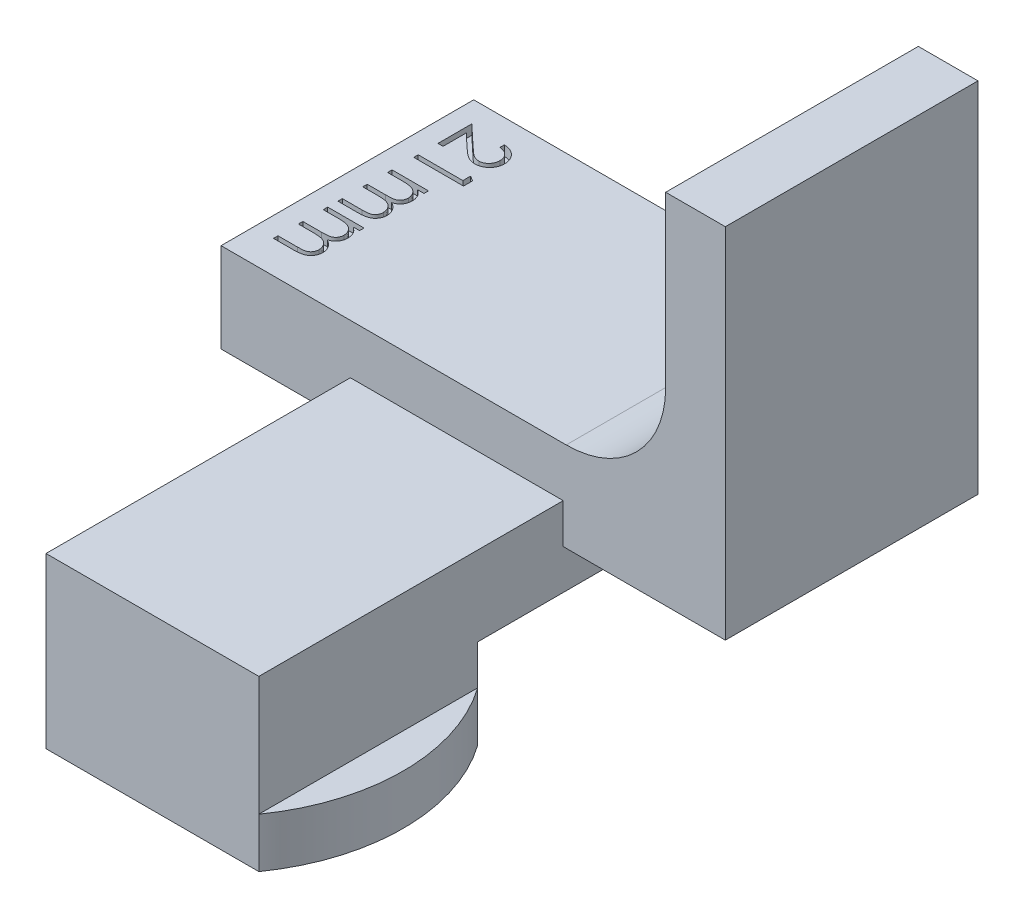
from build123d import *

# Parameters (mm, degrees)
BOSS_EXTRUDE1_DEPTH = 12.7
FILLET1_R           = 5
BOSS_EXTRUDE2_START = -12.7
BOSS_EXTRUDE2_DEPTH = 28
SKETCH4_W           = 14.2
SKETCH4_H           = 4.5
CUT_EXTRUDE2_DEPTH  = 17
SKETCH2_OUTSIDE_W   = 36.354
SKETCH2_OUTSIDE_H   = 39.004
CUT_EXTRUDE1_DEPTH  = 10
CUT_EXTRUDE3_DEPTH  = 0.5


with BuildPart() as part:
    # Sketch1 → Boss-Extrude1 (new body)
    with BuildSketch(Plane.XY):
        Polygon((0, 0), (0, -4), (-1.75, -4), (-1.75, -6.5), (12.45, -6.5), (12.45, -4), (10.7, -4), (10.7, 0), (18.85, 0), (18.85, 18), (15.85, 18), (15.85, 4.5), (-6.5, 4.5), (-6.5, 0), align=None)
    extrude(amount=BOSS_EXTRUDE1_DEPTH)

    # Fillet1
    fillet1_edges = [part.edges().sort_by_distance(p)[0] for p in [
        (15.85, 4.5, 6.35),
    ]]
    fillet(fillet1_edges, radius=FILLET1_R)

    # Sketch3 → Boss-Extrude2 (add)
    with BuildSketch(Plane.XY.offset(12.7).offset(BOSS_EXTRUDE2_START)):
        Polygon((0, 0), (0, 2), (10.7, 2), (10.7, 0), (10.7, -4), (12.45, -4), (12.45, -6.5), (-1.75, -6.5), (-1.75, -4), (0, -4), align=None)
    extrude(amount=BOSS_EXTRUDE2_DEPTH)

    # Sketch4 → Cut-Extrude2 (cut)
    with BuildSketch(Plane(origin=(0, 0, 0), x_dir=(-1, 0, 0), z_dir=(0, 0, -1))):
        with Locations((-5.35, -4.25)):
            Rectangle(SKETCH4_W, SKETCH4_H)
    extrude(amount=-CUT_EXTRUDE2_DEPTH, mode=Mode.SUBTRACT)

    # Sketch2 outside → Cut-Extrude1 (cut)
    with BuildSketch(Plane(origin=(0, -4, 0), x_dir=(1, 0, 0), z_dir=(0, 1, 0))):
        with Locations((6.175, -14)):
            Rectangle(SKETCH2_OUTSIDE_W, SKETCH2_OUTSIDE_H)
        with BuildLine():
            Line((0, -28), (10.7, -28))
            ThreePointArc((10.7, -28), (12.45, -22.5), (10.7, -17))
            Line((10.7, -17), (0, -17))
            ThreePointArc((0, -17), (-1.75, -22.5), (0, -28))
        make_face(mode=Mode.SUBTRACT)
    extrude(amount=-CUT_EXTRUDE1_DEPTH, mode=Mode.SUBTRACT)

    # Sketch5 → Cut-Extrude3 (cut)
    with BuildSketch(Plane(origin=(0, 4.5, 0), x_dir=(1, 0, 0), z_dir=(0, 1, 0))):
        with BuildLine():
            Line((-3.769230769, -1.416666667), (-3.769230769, -1.192307692))
            add(Edge.make_bspline(
                [(-3.769230769, -1.192307692), (-3.739465703, -1.193769696), (-3.681007904, -1.196641031), (-3.595778619, -1.210093331), (-3.514303391, -1.229324068), (-3.437280723, -1.25657851), (-3.363790512, -1.290235363), (-3.294808625, -1.331441091), (-3.229650424, -1.379317255), (-3.169549571, -1.433776024), (-3.114609876, -1.492868808), (-3.06666458, -1.556241548), (-3.026618971, -1.623242893), (-2.992959714, -1.693291702), (-2.967725032, -1.76719811), (-2.948993088, -1.844255655), (-2.93772487, -1.924812628), (-2.936513511, -1.979698296), (-2.935897436, -2.007612179)],
                knots=[0, 0, 0, 0, 8.9345e-05, 0.000175471, 0.000258432, 0.000340159, 0.000420153, 0.000500544, 0.000580775, 0.000662333, 0.000743489, 0.000822516, 0.000900244, 0.000977304, 0.001055226, 0.001134057, 0.001214939, 0.001298647, 0.001298647, 0.001298647, 0.001298647], degree=3))
            add(Edge.make_bspline(
                [(-2.935897436, -2.007612179), (-2.936539191, -2.03502509), (-2.937800215, -2.088890479), (-2.948629522, -2.167506203), (-2.965590659, -2.242347128), (-2.989387385, -2.313266961), (-3.021376262, -2.379699864), (-3.059803075, -2.442144896), (-3.104245812, -2.501345475), (-3.156569964, -2.554636035), (-3.21242881, -2.603570377), (-3.272063027, -2.645786274), (-3.333655374, -2.681938533), (-3.397675518, -2.712072591), (-3.464726252, -2.734255547), (-3.533831397, -2.751097124), (-3.605706262, -2.760616705), (-3.654353802, -2.762077722), (-3.679086538, -2.762820513)],
                knots=[0, 0, 0, 0, 8.2206e-05, 0.000161532, 0.000237582, 0.000312174, 0.000385423, 0.000458258, 0.000531878, 0.000606964, 0.000681872, 0.000754411, 0.000825787, 0.000895917, 0.000966233, 0.001037292, 0.001109039, 0.001183241, 0.001183241, 0.001183241, 0.001183241], degree=3))
            add(Edge.make_bspline(
                [(-3.679086538, -2.762820513), (-3.71390642, -2.761611039), (-3.782935144, -2.759213317), (-3.884374332, -2.738703048), (-3.982655346, -2.706669826), (-4.061753419, -2.668100285), (-4.125491628, -2.629191397), (-4.177969275, -2.594128891), (-4.234473181, -2.553082598), (-4.294814136, -2.505455099), (-4.359464783, -2.452231619), (-4.428386065, -2.392930074), (-4.500865901, -2.327127586), (-4.550369902, -2.280942943), (-4.576021635, -2.257011218)],
                knots=[0, 0, 0, 0, 0.00010437, 0.000206908, 0.000309214, 0.000413814, 0.000469985, 0.000533183, 0.000603103, 0.000679442, 0.000763763, 0.000854314, 0.000952177, 0.001057422, 0.001057422, 0.001057422, 0.001057422], degree=3))
            Line((-4.576021635, -2.257011218), (-5.243589744, -1.631510417))
            Line((-5.243589744, -1.631510417), (-5.243589744, -2.794871795))
            Line((-5.243589744, -2.794871795), (-5.5, -2.794871795))
            Line((-5.5, -2.794871795), (-5.5, -1.096153846))
            Line((-5.5, -1.096153846), (-4.465344551, -2.065705128))
            add(Edge.make_bspline(
                [(-4.465344551, -2.065705128), (-4.440704248, -2.089312433), (-4.393375267, -2.134657234), (-4.324255471, -2.198765658), (-4.260207374, -2.256437951), (-4.200947164, -2.307712368), (-4.146810791, -2.352631099), (-4.097374002, -2.391050425), (-4.053061049, -2.42314015), (-4.001004044, -2.457148572), (-3.937370093, -2.489577858), (-3.85999724, -2.518079883), (-3.780171816, -2.535334621), (-3.726244495, -2.53741506), (-3.69911859, -2.538461538)],
                knots=[0, 0, 0, 0, 0.000102371, 0.000196633, 0.000282807, 0.00036092, 0.00043171, 0.000493817, 0.000548716, 0.000595807, 0.000680247, 0.000762311, 0.000842655, 0.000923972, 0.000923972, 0.000923972, 0.000923972], degree=3))
            add(Edge.make_bspline(
                [(-3.69911859, -2.538461538), (-3.682058563, -2.538012101), (-3.648436526, -2.537126347), (-3.599173745, -2.529161064), (-3.551469794, -2.517458483), (-3.5059145, -2.49942119), (-3.461611877, -2.477750046), (-3.419908864, -2.450063563), (-3.379383905, -2.418425182), (-3.341426566, -2.381726212), (-3.30665175, -2.341437563), (-3.275849492, -2.298868859), (-3.250107098, -2.253833431), (-3.229004646, -2.206518962), (-3.21245079, -2.157057938), (-3.200980379, -2.105354542), (-3.193778604, -2.051551675), (-3.192804196, -2.014813464), (-3.192307692, -1.99609375)],
                knots=[0, 0, 0, 0, 5.1143e-05, 0.000100793, 0.000149379, 0.000198206, 0.000247478, 0.000297068, 0.000348064, 0.000401546, 0.00045516, 0.000507556, 0.000558926, 0.000610487, 0.000662748, 0.000715112, 0.000769155, 0.0008253, 0.0008253, 0.0008253, 0.0008253], degree=3))
            add(Edge.make_bspline(
                [(-3.192307692, -1.99609375), (-3.192818275, -1.976543068), (-3.193820976, -1.938148758), (-3.200839356, -1.881779251), (-3.212935551, -1.827999215), (-3.229519178, -1.776699782), (-3.250398096, -1.727831527), (-3.276905454, -1.681836316), (-3.308006308, -1.638294229), (-3.343459583, -1.597285236), (-3.383118274, -1.559604405), (-3.426783108, -1.525801638), (-3.474738119, -1.496971452), (-3.525900148, -1.471414789), (-3.581629531, -1.451860159), (-3.640575816, -1.43514505), (-3.703576488, -1.423002759), (-3.746982525, -1.418813776), (-3.769230769, -1.416666667)],
                knots=[0, 0, 0, 0, 5.8647e-05, 0.000115173, 0.000170091, 0.000223779, 0.000276715, 0.000329204, 0.000382705, 0.000437025, 0.000491578, 0.000546571, 0.000602313, 0.000659202, 0.000717819, 0.000779181, 0.000842925, 0.000909953, 0.000909953, 0.000909953, 0.000909953], degree=3))
        make_face()
        Polygon((-3, -3.550580929), (-3, -4.012820513), (-5.5, -4.012820513), (-5.5, -3.788461538), (-3.256410256, -3.788461538), (-3.256410256, -3.403846154), align=None)
        with BuildLine():
            Line((-3.673076923, -5.102564103), (-3.673076923, -5.326923077))
            Line((-3.673076923, -5.326923077), (-3.990584936, -5.326923077))
            add(Edge.make_bspline(
                [(-3.990584936, -5.326923077), (-3.962849174, -5.34716972), (-3.90979484, -5.385898498), (-3.839103141, -5.448797063), (-3.780096742, -5.512713891), (-3.748715772, -5.558420094), (-3.733673878, -5.580328526)],
                knots=[0, 0, 0, 0, 0.000102966, 0.000196958, 0.000283467, 0.000363109, 0.000363109, 0.000363109, 0.000363109], degree=3))
            add(Edge.make_bspline(
                [(-3.733673878, -5.580328526), (-3.719384332, -5.610231856), (-3.691054893, -5.66951607), (-3.662316637, -5.763386945), (-3.64465585, -5.85944028), (-3.642240584, -5.92430329), (-3.641025641, -5.95693109)],
                knots=[0, 0, 0, 0, 9.9308e-05, 0.000196881, 0.000293544, 0.000391385, 0.000391385, 0.000391385, 0.000391385], degree=3))
            add(Edge.make_bspline(
                [(-3.641025641, -5.95693109), (-3.641774259, -5.978996712), (-3.643255733, -6.022663392), (-3.652841119, -6.087378046), (-3.669609496, -6.150240939), (-3.692373764, -6.210844306), (-3.720823163, -6.267595926), (-3.753536683, -6.319722966), (-3.790488617, -6.366585325), (-3.833109774, -6.408107089), (-3.882637794, -6.445441216), (-3.940397397, -6.479783522), (-4.007688759, -6.511515734), (-4.056521976, -6.529102395), (-4.082231571, -6.538361378)],
                knots=[0, 0, 0, 0, 6.6199e-05, 0.000131004, 0.000195748, 0.000261045, 0.000324875, 0.00038587, 0.00044539, 0.00050347, 0.000563868, 0.000631031, 0.000704732, 0.000786676, 0.000786676, 0.000786676, 0.000786676], degree=3))
            add(Edge.make_bspline(
                [(-4.082231571, -6.538361378), (-4.064571271, -6.548155129), (-4.029818282, -6.567427856), (-3.980633806, -6.599789024), (-3.934628967, -6.633694597), (-3.891767192, -6.669433505), (-3.852260399, -6.706879695), (-3.815977042, -6.746209064), (-3.782764696, -6.787198937), (-3.743952279, -6.844189786), (-3.702887596, -6.918231383), (-3.666820915, -7.011609342), (-3.644996157, -7.10893871), (-3.642355706, -7.17510418), (-3.641025641, -7.208433494)],
                knots=[0, 0, 0, 0, 6.0564e-05, 0.000119181, 0.000176474, 0.000231939, 0.000286492, 0.000339652, 0.000392367, 0.000444597, 0.000546357, 0.000645594, 0.000744022, 0.000843928, 0.000843928, 0.000843928, 0.000843928], degree=3))
            add(Edge.make_bspline(
                [(-3.641025641, -7.208433494), (-3.642180799, -7.23906311), (-3.644441555, -7.299008243), (-3.662194036, -7.386277718), (-3.692678069, -7.467664722), (-3.734273524, -7.543005491), (-3.786544369, -7.610976786), (-3.848736396, -7.670059864), (-3.920409698, -7.719895838), (-3.987832547, -7.752452009), (-4.047357785, -7.774534341), (-4.098076565, -7.788149508), (-4.153899102, -7.800177862), (-4.214892146, -7.810164466), (-4.281271152, -7.817463431), (-4.352927492, -7.822871085), (-4.429916858, -7.826531138), (-4.483035072, -7.826789761), (-4.510416667, -7.826923077)],
                knots=[0, 0, 0, 0, 9.1843e-05, 0.000179747, 0.000265793, 0.000351646, 0.00043699, 0.000522005, 0.000607999, 0.000697811, 0.000745818, 0.000798306, 0.00085518, 0.000917093, 0.000983624, 0.00105545, 0.001132653, 0.001214791, 0.001214791, 0.001214791, 0.001214791], degree=3))
            Line((-4.510416667, -7.826923077), (-5.5, -7.826923077))
            Line((-5.5, -7.826923077), (-5.5, -7.602564103))
            Line((-5.5, -7.602564103), (-4.509415064, -7.602564103))
            add(Edge.make_bspline(
                [(-4.509415064, -7.602564103), (-4.486043226, -7.602508472), (-4.441126106, -7.602401558), (-4.37666007, -7.600477536), (-4.317896958, -7.596852311), (-4.264916893, -7.592613284), (-4.217596337, -7.586724846), (-4.176030302, -7.579120619), (-4.139891931, -7.571065101), (-4.09983021, -7.557682379), (-4.055638935, -7.536290165), (-4.007972189, -7.503709763), (-3.966512436, -7.462646464), (-3.930306263, -7.415180793), (-3.901462215, -7.361006762), (-3.880083749, -7.301550172), (-3.867445823, -7.237011557), (-3.866083249, -7.192297345), (-3.865384615, -7.169370994)],
                knots=[0, 0, 0, 0, 7.0114e-05, 0.000134748, 0.000193447, 0.000246723, 0.00029418, 0.00033642, 0.000373469, 0.000405143, 0.000462933, 0.000520167, 0.000577538, 0.000637235, 0.000698627, 0.000760882, 0.000826196, 0.000894922, 0.000894922, 0.000894922, 0.000894922], degree=3))
            add(Edge.make_bspline(
                [(-3.865384615, -7.169370994), (-3.866418184, -7.141041216), (-3.868466848, -7.084888039), (-3.888606496, -7.003053701), (-3.919724694, -6.924627707), (-3.964153253, -6.851718167), (-4.017610819, -6.784563992), (-4.081140155, -6.726776322), (-4.15302033, -6.679039661), (-4.219553274, -6.646715238), (-4.279317224, -6.626294332), (-4.331529618, -6.612810815), (-4.390873599, -6.60232268), (-4.456950377, -6.592486587), (-4.530214792, -6.586066782), (-4.610327936, -6.58023223), (-4.697530764, -6.577503042), (-4.757978398, -6.577121286), (-4.789362981, -6.576923077)],
                knots=[0, 0, 0, 0, 8.4849e-05, 0.00016818, 0.000251319, 0.00033712, 0.000423311, 0.000508035, 0.000593596, 0.0006814, 0.000729071, 0.000782881, 0.000842994, 0.000909781, 0.000983233, 0.001063551, 0.001150742, 0.001244898, 0.001244898, 0.001244898, 0.001244898], degree=3))
            Line((-4.789362981, -6.576923077), (-5.5, -6.576923077))
            Line((-5.5, -6.576923077), (-5.5, -6.352564103))
            Line((-5.5, -6.352564103), (-4.571013622, -6.352564103))
            add(Edge.make_bspline(
                [(-4.571013622, -6.352564103), (-4.544803812, -6.352509908), (-4.494378771, -6.352405644), (-4.42207291, -6.350460515), (-4.356287876, -6.34693718), (-4.29718885, -6.342386504), (-4.24461523, -6.337447467), (-4.198739476, -6.329631306), (-4.159370692, -6.321483736), (-4.115774829, -6.3090498), (-4.068483866, -6.287513236), (-4.017684108, -6.25475381), (-3.972914287, -6.214057471), (-3.934949709, -6.165705663), (-3.90383078, -6.111106833), (-3.881062877, -6.051037003), (-3.867930796, -5.985875666), (-3.866249348, -5.940965122), (-3.865384615, -5.91786859)],
                knots=[0, 0, 0, 0, 7.8627e-05, 0.000151271, 0.00021697, 0.000276236, 0.000329108, 0.000375296, 0.000415765, 0.000449679, 0.000511104, 0.000570834, 0.000630394, 0.000691713, 0.000754513, 0.000818227, 0.000883639, 0.000952896, 0.000952896, 0.000952896, 0.000952896], degree=3))
            add(Edge.make_bspline(
                [(-3.865384615, -5.91786859), (-3.866477801, -5.890714153), (-3.868656482, -5.836596325), (-3.888266677, -5.757094916), (-3.918983875, -5.680319438), (-3.961598025, -5.607494611), (-4.014383105, -5.540584666), (-4.076465083, -5.482006737), (-4.147071879, -5.432764324), (-4.212902559, -5.400091429), (-4.271171658, -5.379037283), (-4.320699289, -5.364983294), (-4.375763388, -5.353197643), (-4.436243472, -5.343207902), (-4.50226507, -5.335690764), (-4.573641592, -5.331193303), (-4.65059847, -5.327239971), (-4.703719911, -5.327031299), (-4.731270032, -5.326923077)],
                knots=[0, 0, 0, 0, 8.1352e-05, 0.000162132, 0.000244155, 0.000328761, 0.000414326, 0.000498997, 0.000583882, 0.000671677, 0.000718571, 0.000769613, 0.000825997, 0.000887416, 0.00095345, 0.001025239, 0.001101942, 0.00118458, 0.00118458, 0.00118458, 0.00118458], degree=3))
            Line((-4.731270032, -5.326923077), (-5.5, -5.326923077))
            Line((-5.5, -5.326923077), (-5.5, -5.102564103))
            Line((-5.5, -5.102564103), (-3.673076923, -5.102564103))
        make_face()
        with BuildLine():
            Line((-3.673076923, -8.33974359), (-3.673076923, -8.564102564))
            Line((-3.673076923, -8.564102564), (-3.990584936, -8.564102564))
            add(Edge.make_bspline(
                [(-3.990584936, -8.564102564), (-3.962849174, -8.584349207), (-3.90979484, -8.623077985), (-3.839103141, -8.68597655), (-3.780096742, -8.749893378), (-3.748715772, -8.795599581), (-3.733673878, -8.817508013)],
                knots=[0, 0, 0, 0, 0.000102966, 0.000196958, 0.000283467, 0.000363109, 0.000363109, 0.000363109, 0.000363109], degree=3))
            add(Edge.make_bspline(
                [(-3.733673878, -8.817508013), (-3.719384332, -8.847411343), (-3.691054893, -8.906695557), (-3.662316637, -9.000566432), (-3.64465585, -9.096619767), (-3.642240584, -9.161482777), (-3.641025641, -9.194110577)],
                knots=[0, 0, 0, 0, 9.9308e-05, 0.000196881, 0.000293544, 0.000391385, 0.000391385, 0.000391385, 0.000391385], degree=3))
            add(Edge.make_bspline(
                [(-3.641025641, -9.194110577), (-3.641774259, -9.216176199), (-3.643255733, -9.25984288), (-3.652841119, -9.324557533), (-3.669609496, -9.387420426), (-3.692373764, -9.448023794), (-3.720823163, -9.504775413), (-3.753536683, -9.556902453), (-3.790488617, -9.603764812), (-3.833109774, -9.645286576), (-3.882637794, -9.682620703), (-3.940397397, -9.716963009), (-4.007688759, -9.748695221), (-4.056521976, -9.766281882), (-4.082231571, -9.775540865)],
                knots=[0, 0, 0, 0, 6.6199e-05, 0.000131004, 0.000195748, 0.000261045, 0.000324875, 0.00038587, 0.00044539, 0.00050347, 0.000563868, 0.000631031, 0.000704732, 0.000786676, 0.000786676, 0.000786676, 0.000786676], degree=3))
            add(Edge.make_bspline(
                [(-4.082231571, -9.775540865), (-4.064571271, -9.785334616), (-4.029818282, -9.804607343), (-3.980633806, -9.836968511), (-3.934628967, -9.870874084), (-3.891767192, -9.906612993), (-3.852260399, -9.944059182), (-3.815977042, -9.983388551), (-3.782764696, -10.024378424), (-3.743952279, -10.081369273), (-3.702887596, -10.15541087), (-3.666820915, -10.24878883), (-3.644996157, -10.346118198), (-3.642355706, -10.412283667), (-3.641025641, -10.445612981)],
                knots=[0, 0, 0, 0, 6.0564e-05, 0.000119181, 0.000176474, 0.000231939, 0.000286492, 0.000339652, 0.000392367, 0.000444597, 0.000546357, 0.000645594, 0.000744022, 0.000843928, 0.000843928, 0.000843928, 0.000843928], degree=3))
            add(Edge.make_bspline(
                [(-3.641025641, -10.445612981), (-3.642180799, -10.476242597), (-3.644441555, -10.53618773), (-3.662194036, -10.623457206), (-3.692678069, -10.704844209), (-3.734273524, -10.780184978), (-3.786544369, -10.848156273), (-3.848736396, -10.907239351), (-3.920409698, -10.957075325), (-3.987832547, -10.989631496), (-4.047357785, -11.011713828), (-4.098076565, -11.025328995), (-4.153899102, -11.037357349), (-4.214892146, -11.047343953), (-4.281271152, -11.054642919), (-4.352927492, -11.060050572), (-4.429916858, -11.063710625), (-4.483035072, -11.063969248), (-4.510416667, -11.064102564)],
                knots=[0, 0, 0, 0, 9.1843e-05, 0.000179747, 0.000265793, 0.000351646, 0.00043699, 0.000522005, 0.000607999, 0.000697811, 0.000745818, 0.000798306, 0.00085518, 0.000917093, 0.000983624, 0.00105545, 0.001132653, 0.001214791, 0.001214791, 0.001214791, 0.001214791], degree=3))
            Line((-4.510416667, -11.064102564), (-5.5, -11.064102564))
            Line((-5.5, -11.064102564), (-5.5, -10.83974359))
            Line((-5.5, -10.83974359), (-4.509415064, -10.83974359))
            add(Edge.make_bspline(
                [(-4.509415064, -10.83974359), (-4.486043226, -10.839687959), (-4.441126106, -10.839581045), (-4.37666007, -10.837657023), (-4.317896958, -10.834031798), (-4.264916893, -10.829792772), (-4.217596337, -10.823904333), (-4.176030302, -10.816300107), (-4.139891931, -10.808244588), (-4.09983021, -10.794861866), (-4.055638935, -10.773469652), (-4.007972189, -10.74088925), (-3.966512436, -10.699825951), (-3.930306263, -10.65236028), (-3.901462215, -10.598186249), (-3.880083749, -10.53872966), (-3.867445823, -10.474191045), (-3.866083249, -10.429476832), (-3.865384615, -10.406550481)],
                knots=[0, 0, 0, 0, 7.0114e-05, 0.000134748, 0.000193447, 0.000246723, 0.00029418, 0.00033642, 0.000373469, 0.000405143, 0.000462933, 0.000520167, 0.000577538, 0.000637235, 0.000698627, 0.000760882, 0.000826196, 0.000894922, 0.000894922, 0.000894922, 0.000894922], degree=3))
            add(Edge.make_bspline(
                [(-3.865384615, -10.406550481), (-3.866418184, -10.378220703), (-3.868466848, -10.322067526), (-3.888606496, -10.240233188), (-3.919724694, -10.161807194), (-3.964153253, -10.088897654), (-4.017610819, -10.021743479), (-4.081140155, -9.96395581), (-4.15302033, -9.916219148), (-4.219553274, -9.883894726), (-4.279317224, -9.863473819), (-4.331529618, -9.849990302), (-4.390873599, -9.839502167), (-4.456950377, -9.829666074), (-4.530214792, -9.823246269), (-4.610327936, -9.817411717), (-4.697530764, -9.814682529), (-4.757978398, -9.814300773), (-4.789362981, -9.814102564)],
                knots=[0, 0, 0, 0, 8.4849e-05, 0.00016818, 0.000251319, 0.00033712, 0.000423311, 0.000508035, 0.000593596, 0.0006814, 0.000729071, 0.000782881, 0.000842994, 0.000909781, 0.000983233, 0.001063551, 0.001150742, 0.001244898, 0.001244898, 0.001244898, 0.001244898], degree=3))
            Line((-4.789362981, -9.814102564), (-5.5, -9.814102564))
            Line((-5.5, -9.814102564), (-5.5, -9.58974359))
            Line((-5.5, -9.58974359), (-4.571013622, -9.58974359))
            add(Edge.make_bspline(
                [(-4.571013622, -9.58974359), (-4.544803812, -9.589689396), (-4.494378771, -9.589585131), (-4.42207291, -9.587640002), (-4.356287876, -9.584116667), (-4.29718885, -9.579565992), (-4.24461523, -9.574626954), (-4.198739476, -9.566810793), (-4.159370692, -9.558663223), (-4.115774829, -9.546229287), (-4.068483866, -9.524692723), (-4.017684108, -9.491933297), (-3.972914287, -9.451236958), (-3.934949709, -9.40288515), (-3.90383078, -9.34828632), (-3.881062877, -9.28821649), (-3.867930796, -9.223055153), (-3.866249348, -9.178144609), (-3.865384615, -9.155048077)],
                knots=[0, 0, 0, 0, 7.8627e-05, 0.000151271, 0.00021697, 0.000276236, 0.000329108, 0.000375296, 0.000415765, 0.000449679, 0.000511104, 0.000570834, 0.000630394, 0.000691713, 0.000754513, 0.000818227, 0.000883639, 0.000952896, 0.000952896, 0.000952896, 0.000952896], degree=3))
            add(Edge.make_bspline(
                [(-3.865384615, -9.155048077), (-3.866477801, -9.12789364), (-3.868656482, -9.073775813), (-3.888266677, -8.994274403), (-3.918983875, -8.917498926), (-3.961598025, -8.844674098), (-4.014383105, -8.777764153), (-4.076465083, -8.719186224), (-4.147071879, -8.669943811), (-4.212902559, -8.637270916), (-4.271171658, -8.61621677), (-4.320699289, -8.602162781), (-4.375763388, -8.59037713), (-4.436243472, -8.580387389), (-4.50226507, -8.572870251), (-4.573641592, -8.56837279), (-4.65059847, -8.564419458), (-4.703719911, -8.564210786), (-4.731270032, -8.564102564)],
                knots=[0, 0, 0, 0, 8.1352e-05, 0.000162132, 0.000244155, 0.000328761, 0.000414326, 0.000498997, 0.000583882, 0.000671677, 0.000718571, 0.000769613, 0.000825997, 0.000887416, 0.00095345, 0.001025239, 0.001101942, 0.00118458, 0.00118458, 0.00118458, 0.00118458], degree=3))
            Line((-4.731270032, -8.564102564), (-5.5, -8.564102564))
            Line((-5.5, -8.564102564), (-5.5, -8.33974359))
            Line((-5.5, -8.33974359), (-3.673076923, -8.33974359))
        make_face()
    extrude(amount=-CUT_EXTRUDE3_DEPTH, mode=Mode.SUBTRACT)


solid = part.part
